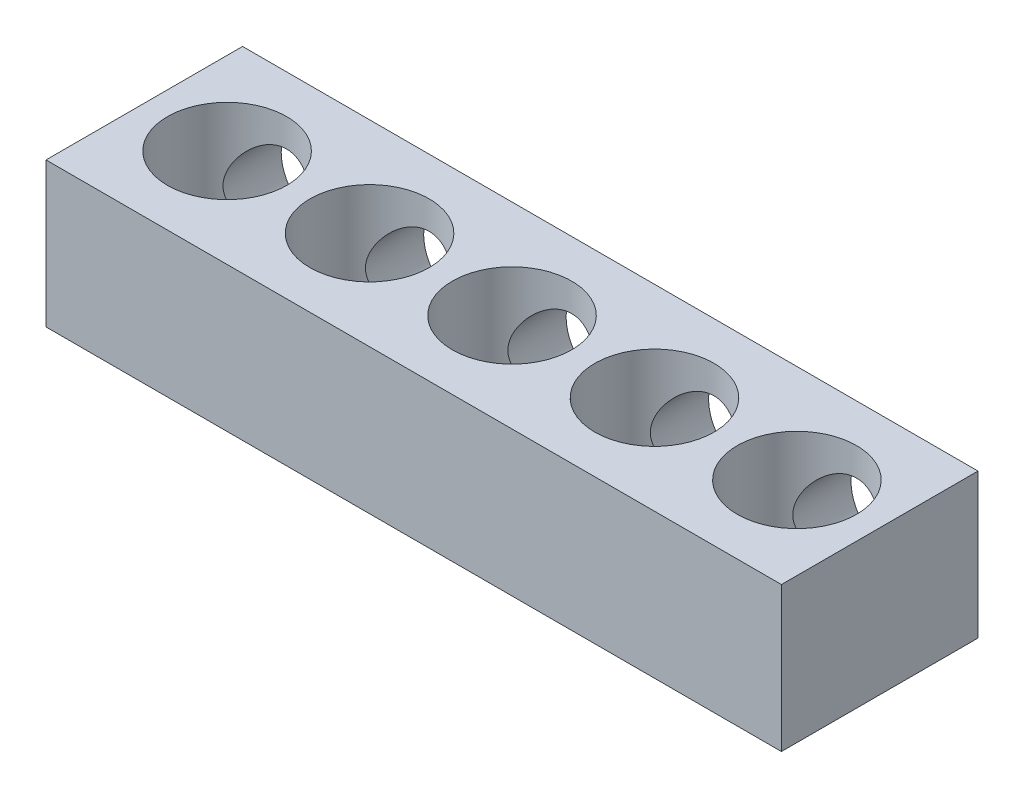
from build123d import *

# Parameters (mm, degrees)
SKETCH1_W           = 33.3
SKETCH1_H           = 8.9
SKETCH1_R           = 2.7
BOSS_EXTRUDE1_DEPTH = 6.55
CUT_EXTRUDE1_REACH  = 10.9
SKETCH2_R           = 2


with BuildPart() as part:
    # Sketch1 → Boss-Extrude1 (new body)
    with BuildSketch(Plane(origin=(0, 0, 0), x_dir=(1, 0, 0), z_dir=(0, 1, 0))):
        Rectangle(SKETCH1_W, SKETCH1_H)
        with Locations((-12.9, 0)):
            Circle(SKETCH1_R, mode=Mode.SUBTRACT)
        with Locations((-6.45, 0)):
            Circle(SKETCH1_R, mode=Mode.SUBTRACT)
        Circle(SKETCH1_R, mode=Mode.SUBTRACT)
        with Locations((6.45, 0)):
            Circle(SKETCH1_R, mode=Mode.SUBTRACT)
        with Locations((12.9, 0)):
            Circle(SKETCH1_R, mode=Mode.SUBTRACT)
    extrude(amount=BOSS_EXTRUDE1_DEPTH)

    # Sketch2 → Cut-Extrude1 (cut, up to next)
    with BuildSketch(Plane(origin=(0, 0, -4.45), x_dir=(-1, 0, 0), z_dir=(0, 0, -1)), mode=Mode.PRIVATE) as cut_extrude1_sk1:
        with Locations((-12.9, 3.275)):
            Circle(SKETCH2_R)
    cut_extrude1_tool1 = extrude(cut_extrude1_sk1.sketch, amount=-CUT_EXTRUDE1_REACH, mode=Mode.PRIVATE) & part.part
    add(cut_extrude1_tool1.solids().sort_by_distance((12.9, 3.275, -4.45))[0], mode=Mode.SUBTRACT)
    # Sketch2 → Cut-Extrude1 (cut, up to next)
    with BuildSketch(Plane(origin=(0, 0, -4.45), x_dir=(-1, 0, 0), z_dir=(0, 0, -1)), mode=Mode.PRIVATE) as cut_extrude1_sk2:
        with Locations((-6.45, 3.275)):
            Circle(SKETCH2_R)
    cut_extrude1_tool2 = extrude(cut_extrude1_sk2.sketch, amount=-CUT_EXTRUDE1_REACH, mode=Mode.PRIVATE) & part.part
    add(cut_extrude1_tool2.solids().sort_by_distance((6.45, 3.275, -4.45))[0], mode=Mode.SUBTRACT)
    # Sketch2 → Cut-Extrude1 (cut, up to next)
    with BuildSketch(Plane(origin=(0, 0, -4.45), x_dir=(-1, 0, 0), z_dir=(0, 0, -1)), mode=Mode.PRIVATE) as cut_extrude1_sk3:
        with Locations((0, 3.275)):
            Circle(SKETCH2_R)
    cut_extrude1_tool3 = extrude(cut_extrude1_sk3.sketch, amount=-CUT_EXTRUDE1_REACH, mode=Mode.PRIVATE) & part.part
    add(cut_extrude1_tool3.solids().sort_by_distance((0, 3.275, -4.45))[0], mode=Mode.SUBTRACT)
    # Sketch2 → Cut-Extrude1 (cut, up to next)
    with BuildSketch(Plane(origin=(0, 0, -4.45), x_dir=(-1, 0, 0), z_dir=(0, 0, -1)), mode=Mode.PRIVATE) as cut_extrude1_sk4:
        with Locations((6.45, 3.275)):
            Circle(SKETCH2_R)
    cut_extrude1_tool4 = extrude(cut_extrude1_sk4.sketch, amount=-CUT_EXTRUDE1_REACH, mode=Mode.PRIVATE) & part.part
    add(cut_extrude1_tool4.solids().sort_by_distance((-6.45, 3.275, -4.45))[0], mode=Mode.SUBTRACT)
    # Sketch2 → Cut-Extrude1 (cut, up to next)
    with BuildSketch(Plane(origin=(0, 0, -4.45), x_dir=(-1, 0, 0), z_dir=(0, 0, -1)), mode=Mode.PRIVATE) as cut_extrude1_sk5:
        with Locations((12.9, 3.275)):
            Circle(SKETCH2_R)
    cut_extrude1_tool5 = extrude(cut_extrude1_sk5.sketch, amount=-CUT_EXTRUDE1_REACH, mode=Mode.PRIVATE) & part.part
    add(cut_extrude1_tool5.solids().sort_by_distance((-12.9, 3.275, -4.45))[0], mode=Mode.SUBTRACT)


solid = part.part
